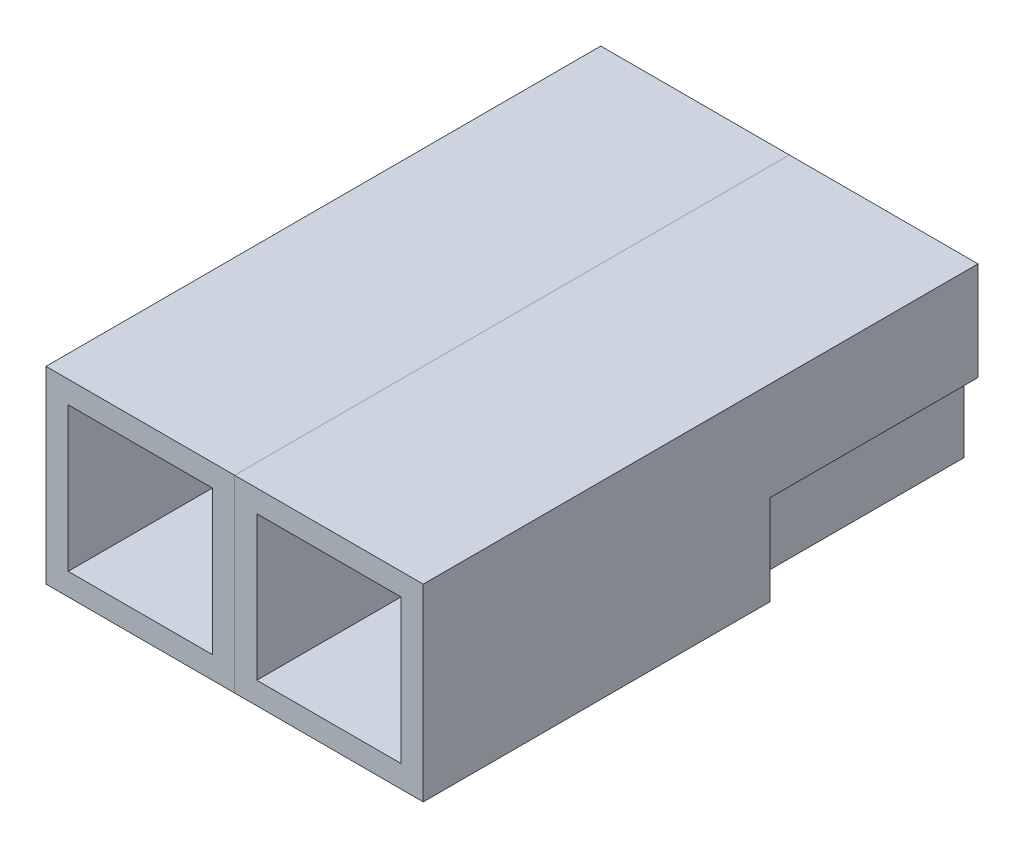
from build123d import *

# Parameters (mm, degrees)
SKETCH1_W       = 8.636
SKETCH1_H       = 8.636
EXTRUDE1_DEPTH  = 25.4
SKETCH2_W       = 6.604
SKETCH2_H       = 6.604
EXTRUDE2_DEPTH  = 12.7
SKETCH3_W       = 7.62
SKETCH3_H       = 4.001867036
EXTRUDE3_DEPTH  = 9.525
EXTRUDE4_DEPTH  = 9.525
LPATTERN1_COUNT = 2
LPATTERN1_PITCH = 8.636


with BuildPart() as part:
    # Sketch1 → Extrude1 (new body)
    with BuildSketch(Plane.XY):
        with Locations((-6.778363288, -5.813462133)):
            Rectangle(SKETCH1_W, SKETCH1_H)
    extrude(amount=EXTRUDE1_DEPTH)

    # Sketch2 → Extrude2 (cut)
    with BuildSketch(Plane.XY.offset(25.4)):
        with Locations((-6.778363288, -5.813462133)):
            Rectangle(SKETCH2_W, SKETCH2_H)
    extrude(amount=-EXTRUDE2_DEPTH, mode=Mode.SUBTRACT)

    # Sketch3 → Extrude3 (cut)
    with BuildSketch(Plane(origin=(0, 0, 0), x_dir=(-1, 0, 0), z_dir=(0, 0, -1))):
        with Locations((6.778363288, -4.004395651)):
            Rectangle(SKETCH3_W, SKETCH3_H)
    extrude(amount=-EXTRUDE3_DEPTH, mode=Mode.SUBTRACT)

    # Sketch4 → Extrude4 (cut)
    with BuildSketch(Plane(origin=(0, 0, 0), x_dir=(-1, 0, 0), z_dir=(0, 0, -1))):
        Polygon((3.095363288, -6.005329169), (3.095363288, -9.496462133), (10.461363288, -9.496462133), (10.461363288, -6.005329169), (11.096363288, -6.005329169), (11.096363288, -10.131462133), (2.460363288, -10.131462133), (2.460363288, -6.005329169), align=None)
    extrude(amount=-EXTRUDE4_DEPTH, mode=Mode.SUBTRACT)


with BuildPart() as lpattern1_1:
    # LPattern1: pattern copy
    add(part.part.moved(Location(Vector(-1, 0, 0) * (1 * LPATTERN1_PITCH))))


solid = Compound([part.part, lpattern1_1.part])
